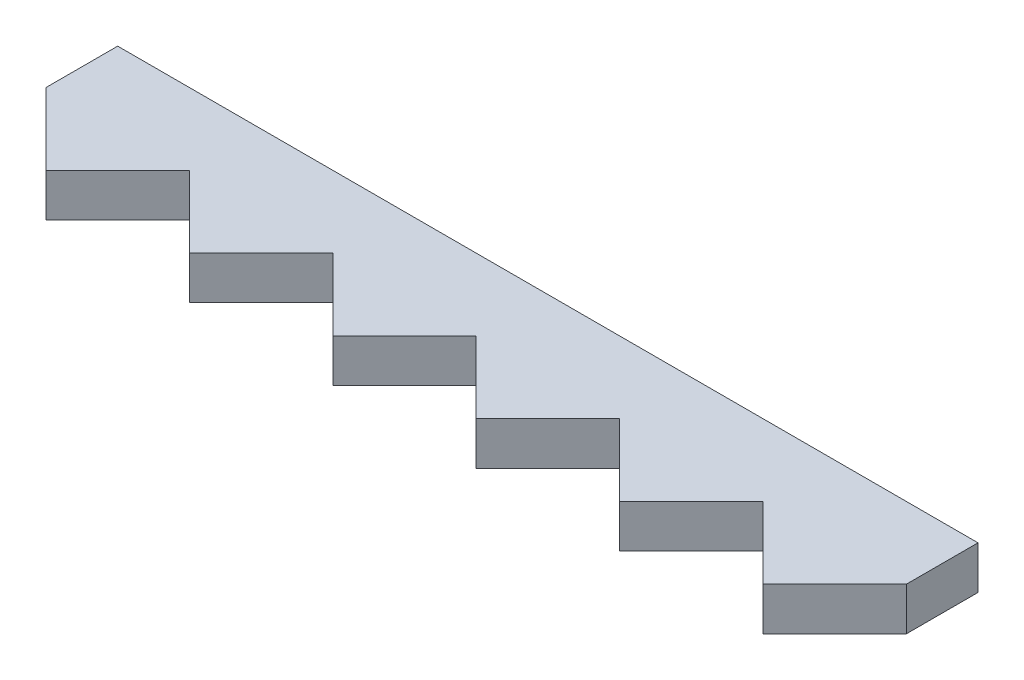
from build123d import *

# Parameters (mm, degrees)
BOSS_EXTRUDE1_DEPTH = 3


with BuildPart() as part:
    # Sketch1 → Boss-Extrude1 (new body)
    with BuildSketch(Plane(origin=(0, 3, 0), x_dir=(1, 0, 0), z_dir=(0, 1, 0))):
        Polygon((0, 71.606428038), (0, 66.606428038), (5, 61.606428038), (10, 66.606428038), (15, 61.606428038), (20, 66.606428038), (25, 61.606428038), (30, 66.606428038), (35, 61.606428038), (40, 66.606428038), (45, 61.606428038), (50, 66.606428038), (55, 61.606428038), (60, 66.606428038), (60, 71.606428038), align=None)
    extrude(amount=BOSS_EXTRUDE1_DEPTH)


solid = part.part
